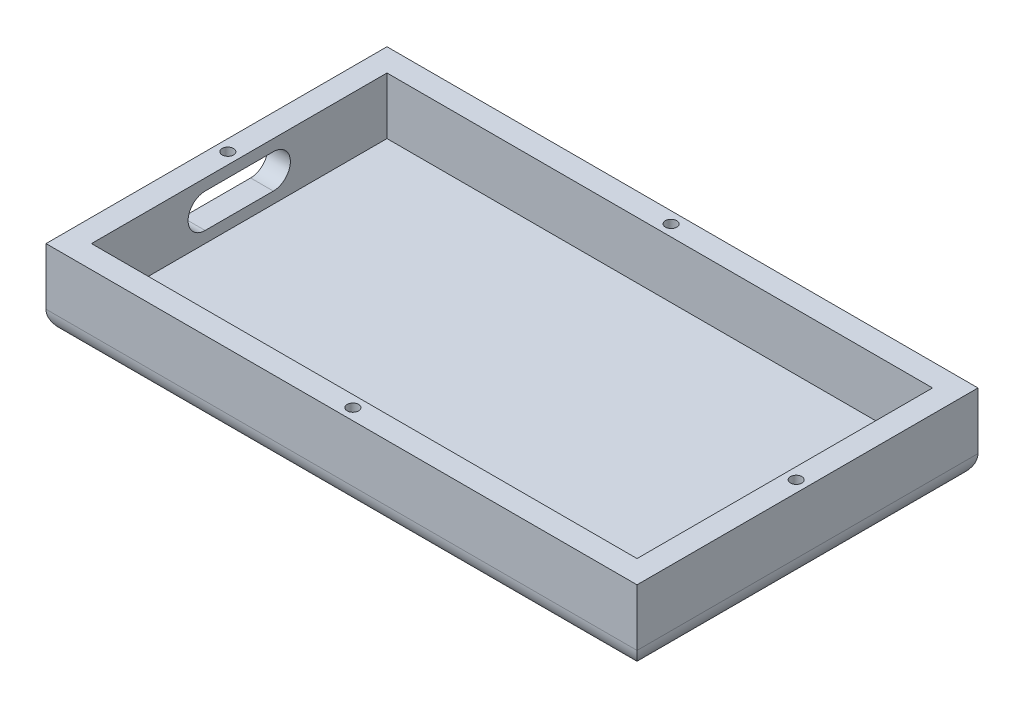
from build123d import *

# Parameters (mm, degrees)
SKETCH1_W           = 66.04
SKETCH1_H           = 38.1
BOSS_EXTRUDE3_DEPTH = 17.78
SKETCH3_W           = 60.96
SKETCH3_H           = 33.02
CUT_EXTRUDE1_DEPTH  = 15.24
SKETCH4_W           = 38.1
SKETCH4_H           = 8.89
CUT_EXTRUDE2_DEPTH  = 66.04
SKETCH5_R           = 0.635
CUT_EXTRUDE3_DEPTH  = 5.08
CUT_EXTRUDE5_DEPTH  = 2.54
FILLET1_R           = 2.54
SKETCH7_R           = 1.5875
CUT_EXTRUDE6_DEPTH  = 1.27


with BuildPart() as part:
    # Sketch1 → Boss-Extrude3 (new body)
    with BuildSketch(Plane(origin=(0, 0, 0), x_dir=(1, 0, 0), z_dir=(0, 1, 0))):
        with Locations((33.02, 19.05)):
            Rectangle(SKETCH1_W, SKETCH1_H)
    extrude(amount=BOSS_EXTRUDE3_DEPTH)

    # Sketch3 → Cut-Extrude1 (cut)
    with BuildSketch(Plane(origin=(0, 17.78, 0), x_dir=(1, 0, 0), z_dir=(0, 1, 0))):
        with Locations((33.02, 19.05)):
            Rectangle(SKETCH3_W, SKETCH3_H)
    extrude(amount=-CUT_EXTRUDE1_DEPTH, mode=Mode.SUBTRACT)

    # Sketch4 → Cut-Extrude2 (cut)
    with BuildSketch(Plane(origin=(66.04, 0, 0), x_dir=(0, 0, -1), z_dir=(1, 0, 0))):
        with Locations((19.05, 13.335)):
            Rectangle(SKETCH4_W, SKETCH4_H)
    extrude(amount=-CUT_EXTRUDE2_DEPTH, mode=Mode.SUBTRACT)

    # Sketch5 → Cut-Extrude3 (cut)
    with BuildSketch(Plane(origin=(0, 8.89, 0), x_dir=(1, 0, 0), z_dir=(0, 1, 0))):
        with Locations((33.02, 36.83)):
            Circle(SKETCH5_R)
        with Locations((33.02, 1.27)):
            Circle(SKETCH5_R)
        with Locations((1.27, 19.05)):
            Circle(SKETCH5_R)
        with Locations((64.77, 19.05)):
            Circle(SKETCH5_R)
    extrude(amount=-CUT_EXTRUDE3_DEPTH, mode=Mode.SUBTRACT)

    # Sketch6 → Cut-Extrude5 (cut)
    with BuildSketch(Plane.ZY):
        with BuildLine():
            Line((-22.86, 7.62), (-15.24, 7.62))
            ThreePointArc((-15.24, 7.62), (-13.335, 5.715), (-15.24, 3.81))
            Line((-15.24, 3.81), (-22.86, 3.81))
            ThreePointArc((-22.86, 3.81), (-24.765, 5.715), (-22.86, 7.62))
        make_face()
    extrude(amount=-CUT_EXTRUDE5_DEPTH, mode=Mode.SUBTRACT)

    # Fillet1
    fillet1_edges = [part.edges().sort_by_distance(p)[0] for p in [
        (33.02, 0, -38.1),
        (66.04, 0, -19.05),
        (33.02, 0, 0),
        (0, 0, -19.05),
    ]]
    fillet(fillet1_edges, radius=FILLET1_R)

    # Sketch7 → Cut-Extrude6 (cut)
    with BuildSketch(Plane.XZ):
        with Locations((33.02, -30.48)):
            Circle(SKETCH7_R)
    extrude(amount=-CUT_EXTRUDE6_DEPTH, mode=Mode.SUBTRACT)


solid = part.part
